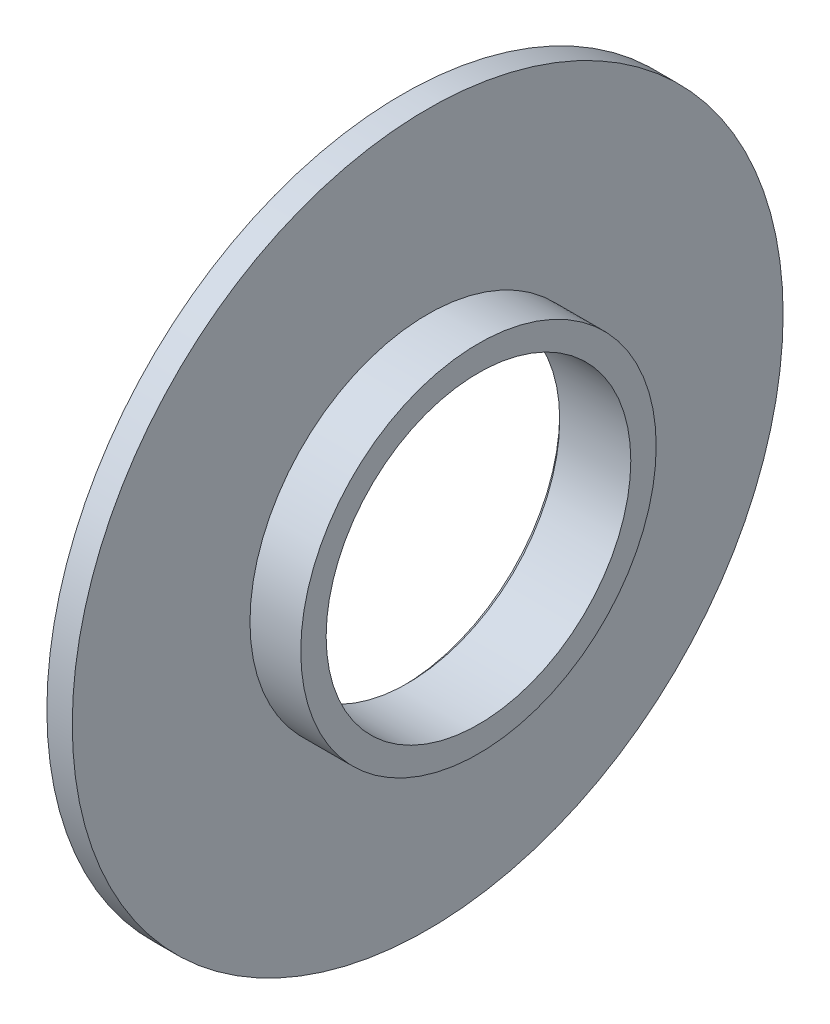
from build123d import *

# Parameters (mm, degrees)
CHAMFER1_SIZE = 0.2


with BuildPart() as part:
    # Sketch1 → Revolve1 (revolve)
    with BuildSketch(Plane.XY):
        Polygon((0, 14), (0, 6), (3, 6), (3, 7), (1, 7), (1, 14), align=None)
    revolve(axis=Axis((0, 0, 0), (1, 0, 0)))

    # Chamfer1
    chamfer1_edges = [part.edges().sort_by_distance(p)[0] for p in [
        (0, -6, 0),
    ]]
    chamfer(chamfer1_edges, length=CHAMFER1_SIZE)


solid = part.part
